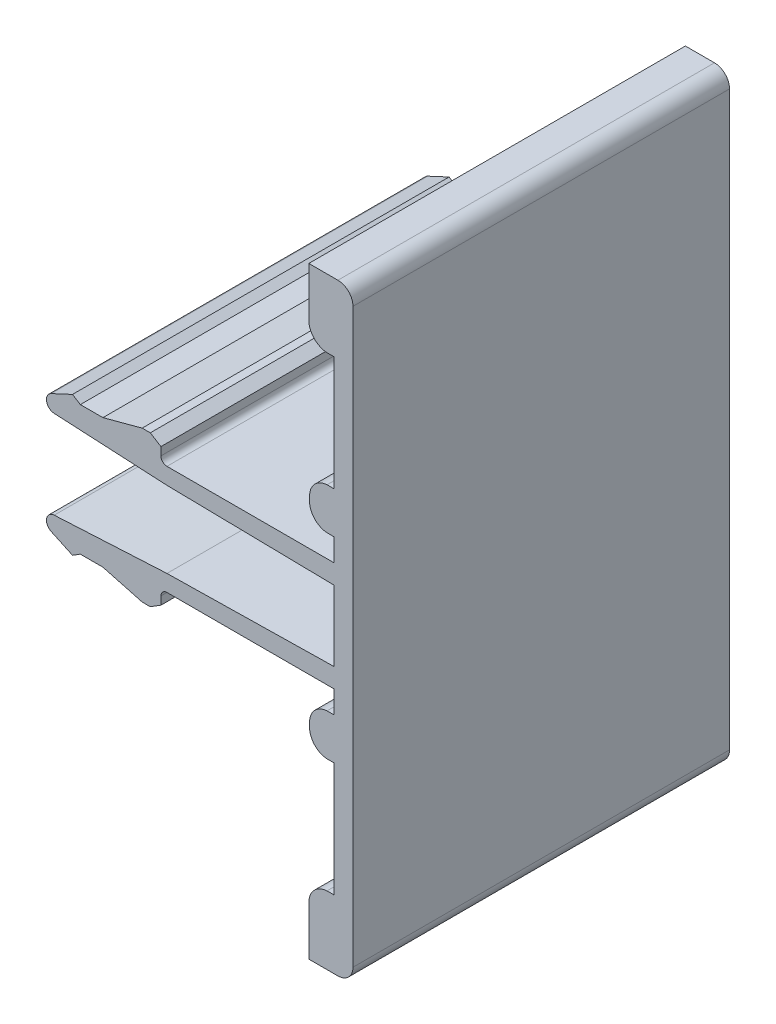
from build123d import *

# Parameters (mm, degrees)
MAIN_EXTRUSION_DEPTH = 25


with BuildPart() as part:
    # Sk Main Extrusion → Main Extrusion (new body)
    with BuildSketch(Plane.XY):
        with BuildLine():
            Line((-3.83, 2.5328), (-11.31249103, 2.925083334))
            ThreePointArc((-11.31249103, 2.925083334), (-11.819967595, 3.366238681), (-11.514691833, 3.965369062))
            Line((-11.514691833, 3.965369062), (-10.100108722, 4.625))
            Line((-10.100108722, 4.625), (-9.58, 4.3))
            Line((-9.58, 4.3), (-8.08, 4.3))
            Line((-8.08, 4.3), (-5.474147193, 5))
            Line((-5.474147193, 5), (-4.934147193, 5))
            Line((-4.934147193, 5), (-4.23, 4.56))
            Line((-4.23, 4.56), (-4.23, 4.025))
            ThreePointArc((-4.23, 4.025), (-4.112842712, 3.742157288), (-3.83, 3.625))
            Line((-3.83, 3.625), (7.27, 3.625))
            Line((7.27, 3.625), (7.27, 5.120055168))
            Line((7.27, 5.120055168), (6.79886836, 5.120055168))
            ThreePointArc((6.79886836, 5.120055168), (5.9740485, 5.504367154), (5.638, 6.35))
            Line((5.638, 6.35), (5.638, 6.65))
            ThreePointArc((5.638, 6.65), (5.9740485, 7.495632846), (6.79886836, 7.879944832))
            Line((6.79886836, 7.879944832), (7.27, 7.879944832))
            Line((7.27, 7.879944832), (7.27, 15.470020156))
            Line((7.27, 15.470020156), (6.798058361, 15.470020156))
            ThreePointArc((6.798058361, 15.470020156), (5.938401057, 15.86929153), (5.588, 16.75))
            Line((5.588, 16.75), (5.588, 20))
            Line((5.588, 20), (7.52, 20))
            ThreePointArc((7.52, 20), (8.227106781, 19.707106781), (8.52, 19))
            Line((8.52, 19), (8.52, -19))
            ThreePointArc((8.52, -19), (8.227106781, -19.707106781), (7.52, -20))
            Line((7.52, -20), (5.588, -20))
            Line((5.588, -20), (5.588, -16.75))
            ThreePointArc((5.588, -16.75), (5.938401057, -15.86929153), (6.798058361, -15.470020156))
            Line((6.798058361, -15.470020156), (7.27, -15.470020156))
            Line((7.27, -15.470020156), (7.27, -7.879944832))
            Line((7.27, -7.879944832), (6.79886836, -7.879944832))
            ThreePointArc((6.79886836, -7.879944832), (5.9740485, -7.495632846), (5.638, -6.65))
            Line((5.638, -6.65), (5.638, -6.35))
            ThreePointArc((5.638, -6.35), (5.9740485, -5.504367154), (6.79886836, -5.120055168))
            Line((6.79886836, -5.120055168), (7.27, -5.120055168))
            Line((7.27, -5.120055168), (7.27, -3.625))
            Line((7.27, -3.625), (-3.83, -3.625))
            ThreePointArc((-3.83, -3.625), (-4.112842712, -3.742157288), (-4.23, -4.025))
            Line((-4.23, -4.025), (-4.23, -4.56))
            Line((-4.23, -4.56), (-4.934147193, -5))
            Line((-4.934147193, -5), (-5.474147193, -5))
            Line((-5.474147193, -5), (-8.08, -4.3))
            Line((-8.08, -4.3), (-9.58, -4.3))
            Line((-9.58, -4.3), (-10.100108722, -4.625))
            Line((-10.100108722, -4.625), (-11.514691833, -3.965369062))
            ThreePointArc((-11.514691833, -3.965369062), (-11.819967595, -3.366238681), (-11.31249103, -2.925083334))
            Line((-11.31249103, -2.925083334), (-3.83, -2.5328))
            Line((-3.83, -2.5328), (7.27, -2.339048779))
            Line((7.27, -2.339048779), (7.27, 2.339048779))
            Line((7.27, 2.339048779), (-3.83, 2.5328))
        make_face()
    extrude(amount=-MAIN_EXTRUSION_DEPTH)


solid = part.part
